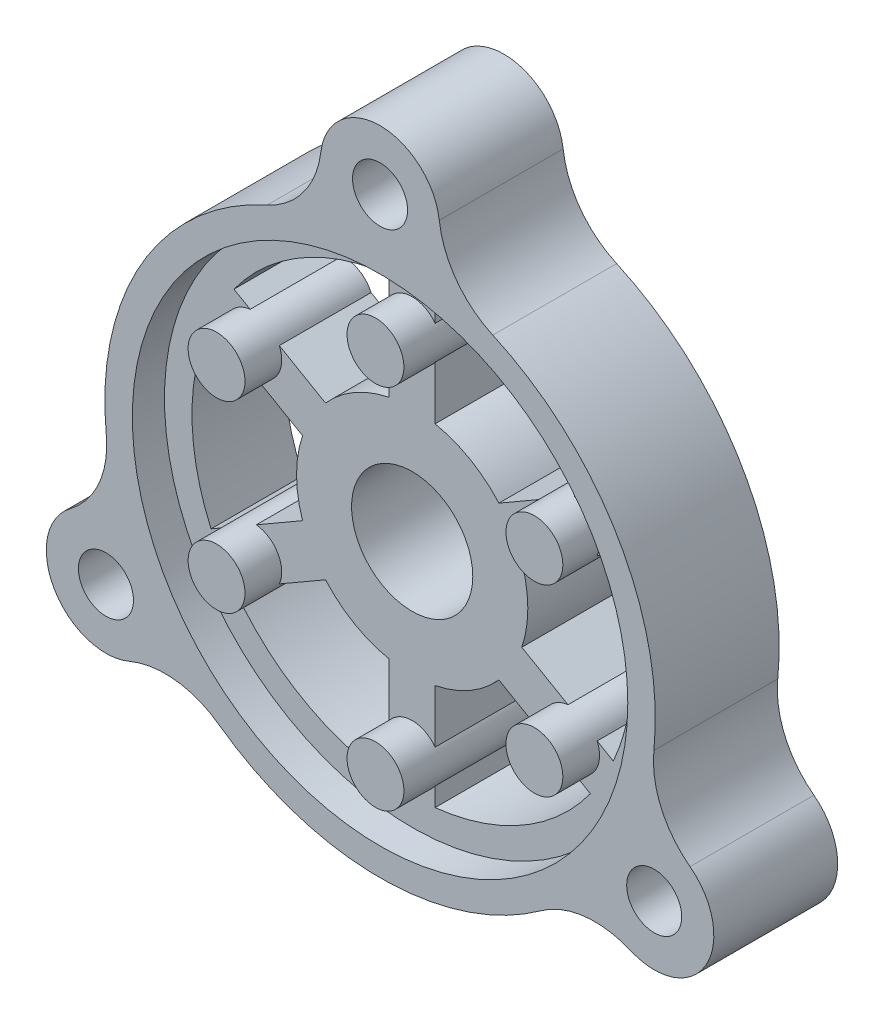
from build123d import *

# Parameters (mm, degrees)
SKETCH1_R                = 15
BOSS_EXTRUDE1_DEPTH      = 5
SKETCH2_R                = 12
SKETCH2_R_2              = 6.302
SKETCH2_R_3              = 3.302
CUT_EXTRUDE1_DEPTH       = 22.794494718
SKETCH4_R                = 1.55
BOSS_EXTRUDE2_DEPTH      = 7
BOSS_EXTRUDE2_2_DEPTH    = 7
BOSS_EXTRUDE2_3_DEPTH    = 7
BOSS_EXTRUDE2_4_DEPTH    = 7
BOSS_EXTRUDE2_5_DEPTH    = 7
BOSS_EXTRUDE2_6_DEPTH    = 7
SKETCH5_W                = 2.5
SKETCH5_H                = 8.771038414
BOSS_EXTRUDE3_DEPTH      = 5
CIRPATTERN1_COUNT        = 6
SKETCH6_R                = 15
SKETCH6_R_2              = 13.5
BOSS_EXTRUDE4_DEPTH      = 1.75
SKETCH7_R                = 3.25
SKETCH7_R_2              = 1.5
BOSS_EXTRUDE5_DEPTH      = 6.75
FILLET2_R                = 5
CIRPATTERN2_COUNT        = 3
FILLET2_OF_CIRPATTERN2_R = 5


with BuildPart() as part:
    # Sketch1 → Boss-Extrude1 (new body)
    with BuildSketch(Plane.XY):
        Circle(SKETCH1_R)
    extrude(amount=BOSS_EXTRUDE1_DEPTH)

    # Sketch2 → Cut-Extrude1 (cut, through all)
    with BuildSketch(Plane.XY.offset(5)):
        Circle(SKETCH2_R)
        Circle(SKETCH2_R_2, mode=Mode.SUBTRACT)
        Circle(SKETCH2_R_3)
    extrude(amount=-CUT_EXTRUDE1_DEPTH, mode=Mode.SUBTRACT)


with BuildPart() as cut_extrude1_piece_1:
    # of the separate pieces the step leaves, piece 1, a body of its own (cut_extrude1_pieces)
    add(part.part.solids().sort_by_distance((15, 0, 0))[0])



with BuildPart() as cut_extrude1_piece_2:
    # of the separate pieces the step leaves, piece 2, a body of its own (cut_extrude1_pieces)
    add(part.part.solids().sort_by_distance((6.302, 0, 0))[0])


with BuildPart() as body_3:
    # Sketch4 → Boss-Extrude2 (new body)
    with BuildSketch(Plane.XY):
        with Locations((0, 10)):
            Circle(SKETCH4_R)
    extrude(amount=BOSS_EXTRUDE2_DEPTH)


with BuildPart() as body_4:
    # Sketch4 → Boss-Extrude2 2 (new body)
    with BuildSketch(Plane.XY):
        with Locations((-8.660254038, 5)):
            Circle(SKETCH4_R)
    extrude(amount=BOSS_EXTRUDE2_2_DEPTH)


with BuildPart() as body_5:
    # Sketch4 → Boss-Extrude2 3 (new body)
    with BuildSketch(Plane.XY):
        with Locations((-8.660254038, -5)):
            Circle(SKETCH4_R)
    extrude(amount=BOSS_EXTRUDE2_3_DEPTH)


with BuildPart() as body_6:
    # Sketch4 → Boss-Extrude2 4 (new body)
    with BuildSketch(Plane.XY):
        with Locations((0, -10)):
            Circle(SKETCH4_R)
    extrude(amount=BOSS_EXTRUDE2_4_DEPTH)


with BuildPart() as body_7:
    # Sketch4 → Boss-Extrude2 5 (new body)
    with BuildSketch(Plane.XY):
        with Locations((8.660254038, -5)):
            Circle(SKETCH4_R)
    extrude(amount=BOSS_EXTRUDE2_5_DEPTH)


with BuildPart() as body_8:
    # Sketch4 → Boss-Extrude2 6 (new body)
    with BuildSketch(Plane.XY):
        with Locations((8.660254038, 5)):
            Circle(SKETCH4_R)
    extrude(amount=BOSS_EXTRUDE2_6_DEPTH)



with BuildPart() as cut_extrude1_piece_1_1:
    add(cut_extrude1_piece_1.part)

    add(cut_extrude1_piece_2.part)  # Boss-Extrude3 merges Cut-Extrude1 piece 2
    # Sketch5 → Boss-Extrude3 (add)
    with BuildSketch(Plane(origin=(0, 0, 0), x_dir=(-1, 0, 0), z_dir=(0, 0, -1))):
        with Locations((0, 10.562306722)):
            Rectangle(SKETCH5_W, SKETCH5_H)
    boss_extrude3 = extrude(amount=-BOSS_EXTRUDE3_DEPTH)

    # CirPattern1: Boss-Extrude3 ×6 about axis
    cirpattern1_axis = Axis((0, 0, 0), (0, 0, 1))
    for i in range(1, CIRPATTERN1_COUNT):
        add(boss_extrude3.rotate(cirpattern1_axis, i * 360 / CIRPATTERN1_COUNT))


with BuildPart() as body_8_1:
    add(body_8.part)

    add(cut_extrude1_piece_1_1.part)  # Boss-Extrude4 merges Cut-Extrude1 piece 1

    add(body_3.part)  # Boss-Extrude4 merges body 3

    add(body_4.part)  # Boss-Extrude4 merges body 4

    add(body_5.part)  # Boss-Extrude4 merges body 5

    add(body_6.part)  # Boss-Extrude4 merges body 6

    add(body_7.part)  # Boss-Extrude4 merges body 7
    # Sketch6 → Boss-Extrude4 (add)
    with BuildSketch(Plane.XY.offset(5)):
        Circle(SKETCH6_R)
        Circle(SKETCH6_R_2, mode=Mode.SUBTRACT)
    extrude(amount=BOSS_EXTRUDE4_DEPTH)

    # Sketch7 → Boss-Extrude5 (add)
    with BuildSketch(Plane(origin=(0, 0, 0), x_dir=(-1, 0, 0), z_dir=(0, 0, -1))):
        with Locations((0, 17.25)):
            Circle(SKETCH7_R)
        with Locations((0, 17.25)):
            Circle(SKETCH7_R_2, mode=Mode.SUBTRACT)
    boss_extrude5 = extrude(amount=-BOSS_EXTRUDE5_DEPTH)

    # Fillet2
    fillet2_edges = [body_8_1.edges().sort_by_distance(p)[0] for p in [
        (2.181099234, 14.84057971, 3.375),
        (-2.181099234, 14.84057971, 3.375),
    ]]
    fillet(fillet2_edges, radius=FILLET2_R)

    # CirPattern2: Boss-Extrude5 ×3 about axis
    cirpattern2_axis = Axis((0, 0, 0), (0, 0, 1))
    for i in range(1, CIRPATTERN2_COUNT):
        add(boss_extrude5.rotate(cirpattern2_axis, i * 360 / CIRPATTERN2_COUNT))

    # Fillet2 of CirPattern2
    fillet2_of_cirpattern2_edges = [body_8_1.edges().sort_by_distance(p)[0] for p in [
        (-13.942868653, -5.531402511, 3.375),
        (-11.761769419, -9.3091772, 3.375),
        (11.761769419, -9.3091772, 3.375),
        (13.942868653, -5.531402511, 3.375),
    ]]
    fillet(fillet2_of_cirpattern2_edges, radius=FILLET2_OF_CIRPATTERN2_R)


solid = body_8_1.part
